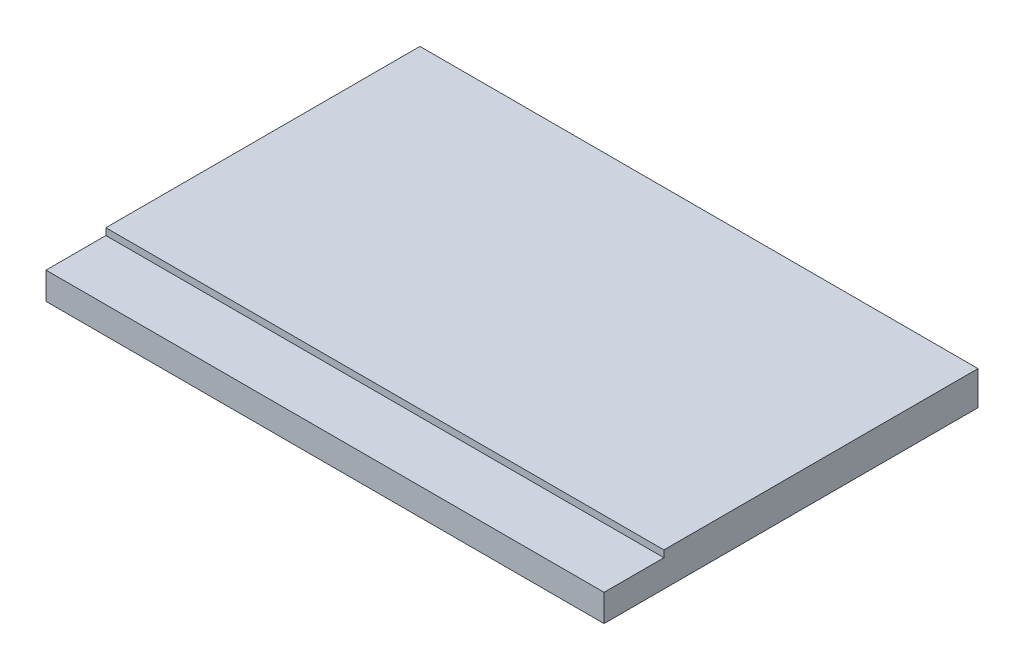
from build123d import *

# Parameters (mm, degrees)
SKETCH1_W           = 24.7
SKETCH1_H           = 16.55
BOSS_EXTRUDE1_DEPTH = 1.5
SKETCH2_W           = 24.7
SKETCH2_H           = 2.65
CUT_EXTRUDE1_DEPTH  = 0.3


with BuildPart() as part:
    # Sketch1 → Boss-Extrude1 (new body)
    with BuildSketch(Plane(origin=(0, 0, 0), x_dir=(1, 0, 0), z_dir=(0, 1, 0))):
        Rectangle(SKETCH1_W, SKETCH1_H)
    extrude(amount=BOSS_EXTRUDE1_DEPTH)

    # Sketch2 → Cut-Extrude1 (cut)
    with BuildSketch(Plane(origin=(0, 1.5, 0), x_dir=(1, 0, 0), z_dir=(0, 1, 0))):
        with Locations((0, -6.95)):
            Rectangle(SKETCH2_W, SKETCH2_H)
    extrude(amount=-CUT_EXTRUDE1_DEPTH, mode=Mode.SUBTRACT)


solid = part.part
